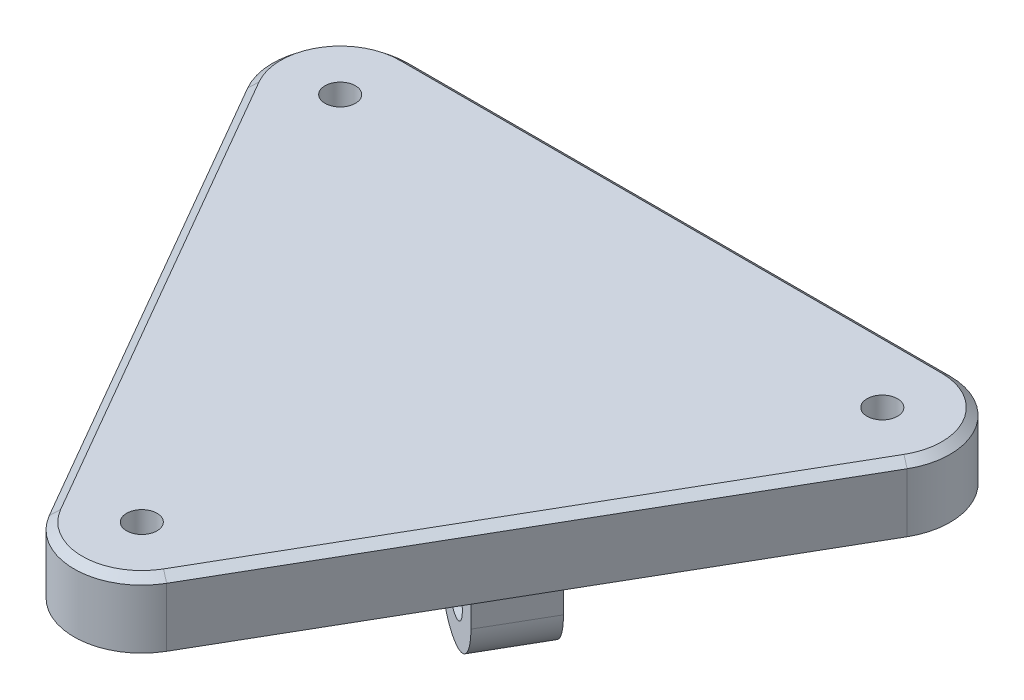
from build123d import *
from OCP.BRepFilletAPI import BRepFilletAPI_MakeChamfer

# Parameters (mm, degrees)
BOSS_EXTRUDE3_DEPTH            = 10
SKETCH13_W                     = 10
SKETCH13_H                     = 12
BOSS_EXTRUDE5_DEPTH            = 20
SKETCH15_R                     = 2.55
CUT_EXTRUDE7_DEPTH             = 82.299792521
CBORE_FOR_M4_SHCS1_D           = 4.5
CBORE_FOR_M4_SHCS1_DEPTH       = 15.5
CBORE_FOR_M4_SHCS1_CBORE_D     = 8
CBORE_FOR_M4_SHCS1_CBORE_DEPTH = 4
CBORE_FOR_M4_SHCS1_TIP         = 1.351936393
SKETCH21_R                     = 1.118017303
BOSS_EXTRUDE6_DEPTH            = 1
CIRPATTERN3_COUNT              = 3
SKETCH22_R                     = 1.118017303
CUT_EXTRUDE8_DEPTH             = 1
FILLET1_R                      = 4
CHAMFER1_SIZE                  = 1
CHAMFER1_SIZE2                 = 1.227870321
CHAMFER2_SIZE                  = 1
CHAMFER2_SIZE2                 = 0.307449129


with BuildPart() as part:
    # Sketch6 → Boss-Extrude3 (new body)
    with BuildSketch(Plane(origin=(0, 0, 0), x_dir=(1, 0, 0), z_dir=(0, 1, 0))):
        with BuildLine():
            Line((-40, 33.094010768), (40, 33.094010768))
            ThreePointArc((40, 33.094010768), (48.660254038, 28.094010768), (48.660254038, 18.094010768))
            Line((48.660254038, 18.094010768), (28.660254038, -16.547005384))
            Line((28.660254038, -16.547005384), (8.660254038, -51.188021535))
            ThreePointArc((8.660254038, -51.188021535), (0, -56.188021535), (-8.660254038, -51.188021535))
            Line((-8.660254038, -51.188021535), (-28.660254038, -16.547005384))
            Line((-28.660254038, -16.547005384), (-48.660254038, 18.094010768))
            ThreePointArc((-48.660254038, 18.094010768), (-48.660254038, 28.094010768), (-40, 33.094010768))
        make_face()
    extrude(amount=BOSS_EXTRUDE3_DEPTH)

    # Sketch13 → Boss-Extrude5 (add)
    with BuildSketch(Plane(origin=(0, 0, 0), x_dir=(-1, 0, 0), z_dir=(0, -1, 0))):
        with Locations((-0.25, 20.094010768)):
            Rectangle(SKETCH13_W, SKETCH13_H)
    boss_extrude5 = extrude(amount=BOSS_EXTRUDE5_DEPTH)

    # Sketch15 → Cut-Extrude7 (cut, through all)
    with BuildSketch(Plane(origin=(5.25, 0, 0), x_dir=(0, 0, -1), z_dir=(1, 0, 0))):
        with Locations((20.094010768, -8)):
            Circle(SKETCH15_R)
        with BuildLine():
            Line((14.094010768, -8), (14.094010768, -20))
            Line((14.094010768, -20), (26.094010768, -20))
            Line((26.094010768, -20), (26.094010768, -8))
            ThreePointArc((26.094010768, -8), (20.094010768, -14), (14.094010768, -8))
        make_face()
    cut_extrude7 = extrude(amount=-CUT_EXTRUDE7_DEPTH, mode=Mode.SUBTRACT)

    # CBORE for M4 SHCS1
    with Locations(Plane(origin=(0, 0, 0), x_dir=(-1, 0, 0), z_dir=(0, -1, 0))):
        with Locations((-40, 23.094010768), (40, 23.094010768), (0, -46.188021535)):
            CounterBoreHole(CBORE_FOR_M4_SHCS1_D / 2, CBORE_FOR_M4_SHCS1_CBORE_D / 2, CBORE_FOR_M4_SHCS1_CBORE_DEPTH, depth=CBORE_FOR_M4_SHCS1_DEPTH)
            with Locations((0, 0, -(CBORE_FOR_M4_SHCS1_DEPTH + CBORE_FOR_M4_SHCS1_TIP / 2))):  # 118° drill point
                Cone(0, CBORE_FOR_M4_SHCS1_D / 2, CBORE_FOR_M4_SHCS1_TIP, mode=Mode.SUBTRACT)

    # Sketch21 → Boss-Extrude6 (add)
    with BuildSketch(Plane(origin=(0, 0, 0), x_dir=(-1, 0, 0), z_dir=(0, -1, 0))):
        with Locations(Location((0, 0, 0), (0, 0, 270))):
            Circle(SKETCH21_R)
    boss_extrude6 = extrude(amount=BOSS_EXTRUDE6_DEPTH)

    # CirPattern3: Boss-Extrude5, Cut-Extrude7, Boss-Extrude6 ×3 about axis
    cirpattern3_axis = Axis((0, 0, 0), (0, 1, 0))
    add([boss_extrude5.rotate(cirpattern3_axis, i * 360 / CIRPATTERN3_COUNT) for i in range(1, CIRPATTERN3_COUNT)])
    add([cut_extrude7.rotate(cirpattern3_axis, i * 360 / CIRPATTERN3_COUNT) for i in range(1, CIRPATTERN3_COUNT)], mode=Mode.SUBTRACT)
    add([boss_extrude6.rotate(cirpattern3_axis, i * 360 / CIRPATTERN3_COUNT) for i in range(1, CIRPATTERN3_COUNT)])

    # Sketch22 → Cut-Extrude8 (cut)
    with BuildSketch(Plane(origin=(0, -1, 0), x_dir=(-1, 0, 0), z_dir=(0, -1, 0))):
        Circle(SKETCH22_R)
    extrude(amount=-CUT_EXTRUDE8_DEPTH, mode=Mode.SUBTRACT)

    # Fillet1
    fillet1_edges = [part.edges().sort_by_distance(p)[0] for p in [
        (-12.330771366, 0, 6.830499033),
        (-15.026923789, 0, 14.160626052),
        (-22.723076211, 0, 12.830499033),
        (-20.026923789, 0, 5.500372014),
        (0.25, 0, -14.094010768),
        (-4.75, 0, -20.094010768),
        (0.25, 0, -26.094010768),
        (5.25, 0, -20.094010768),
        (12.080771366, 0, 7.263511735),
        (19.776923789, 0, 5.933384716),
        (22.473076211, 0, 13.263511735),
        (14.776923789, 0, 14.593638754),
    ]]
    fillet(fillet1_edges, radius=FILLET1_R)

    # Chamfer1: one chamfer whose edges measure the first distance from different faces: ONE call of the kernel's chamfer builder (chamfer() names one face for all edges)
    chamfer1_edges_1 = [part.edges().sort_by_distance(p)[0] for p in [
        (-48.660254038, 10, -28.094010768),
    ]]
    chamfer1_side_1 = [part.faces().sort_by_distance(p)[0] for p in [
        (-48.660254038, 5, -28.094010768),
    ]]
    chamfer1_edges_2 = [part.edges().sort_by_distance(p)[0] for p in [
        (-28.660254038, 10, 16.547005384),
    ]]
    chamfer1_side_2 = [part.faces().sort_by_distance(p)[0] for p in [
        (-28.660254038, 5, 16.547005384),
    ]]
    chamfer1_edges_3 = [part.edges().sort_by_distance(p)[0] for p in [
        (0, 10, 56.188021535),
    ]]
    chamfer1_side_3 = [part.faces().sort_by_distance(p)[0] for p in [
        (0, 5, 56.188021535),
    ]]
    chamfer1_edges_4 = [part.edges().sort_by_distance(p)[0] for p in [
        (28.660254038, 10, 16.547005384),
    ]]
    chamfer1_side_4 = [part.faces().sort_by_distance(p)[0] for p in [
        (28.660254038, 5, 16.547005384),
    ]]
    chamfer1_edges_5 = [part.edges().sort_by_distance(p)[0] for p in [
        (48.660254038, 10, -28.094010768),
    ]]
    chamfer1_side_5 = [part.faces().sort_by_distance(p)[0] for p in [
        (48.660254038, 5, -28.094010768),
    ]]
    chamfer1_edges_6 = [part.edges().sort_by_distance(p)[0] for p in [
        (0, 10, -33.094010768),
    ]]
    chamfer1_side_6 = [part.faces().sort_by_distance(p)[0] for p in [
        (0, 5, -33.094010768),
    ]]
    chamfer1 = BRepFilletAPI_MakeChamfer(part.part.solid().wrapped)
    for e in chamfer1_edges_1:
        chamfer1.Add(CHAMFER1_SIZE, CHAMFER1_SIZE2, e.wrapped, chamfer1_side_1[0].wrapped)  # the first distance lies on this face
    for e in chamfer1_edges_2:
        chamfer1.Add(CHAMFER1_SIZE, CHAMFER1_SIZE2, e.wrapped, chamfer1_side_2[0].wrapped)  # the first distance lies on this face
    for e in chamfer1_edges_3:
        chamfer1.Add(CHAMFER1_SIZE, CHAMFER1_SIZE2, e.wrapped, chamfer1_side_3[0].wrapped)  # the first distance lies on this face
    for e in chamfer1_edges_4:
        chamfer1.Add(CHAMFER1_SIZE, CHAMFER1_SIZE2, e.wrapped, chamfer1_side_4[0].wrapped)  # the first distance lies on this face
    for e in chamfer1_edges_5:
        chamfer1.Add(CHAMFER1_SIZE, CHAMFER1_SIZE2, e.wrapped, chamfer1_side_5[0].wrapped)  # the first distance lies on this face
    for e in chamfer1_edges_6:
        chamfer1.Add(CHAMFER1_SIZE, CHAMFER1_SIZE2, e.wrapped, chamfer1_side_6[0].wrapped)  # the first distance lies on this face
    add(Compound.cast(chamfer1.Shape()), mode=Mode.REPLACE)

    # Chamfer2
    chamfer2_edges = [part.edges().sort_by_distance(p)[0] for p in [
        (-48.660254038, 0, -28.094010768),
        (0, 0, -33.094010768),
        (48.660254038, 0, -28.094010768),
        (28.660254038, 0, 16.547005384),
        (0, 0, 56.188021535),
        (-28.660254038, 0, 16.547005384),
    ]]
    chamfer2_side = [part.faces().sort_by_distance(p)[0] for p in [
        (0, 0, 0),
    ]]
    chamfer(chamfer2_edges, length=CHAMFER2_SIZE, length2=CHAMFER2_SIZE2, reference=chamfer2_side[0])


solid = part.part
